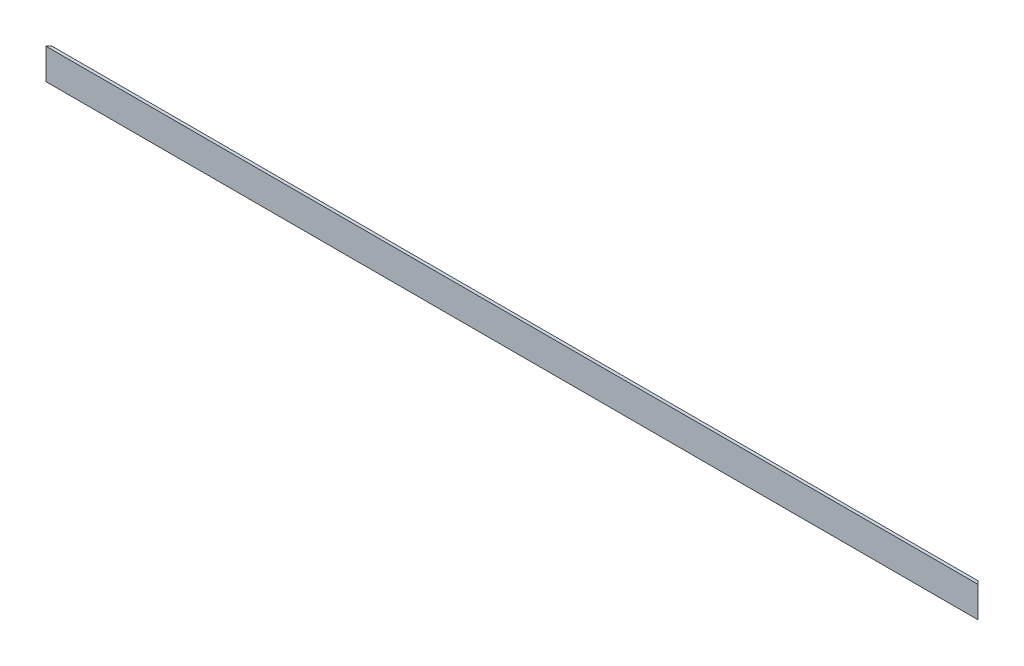
from build123d import *

# Parameters (mm, degrees)
EXTRUDE_1_DEPTH     = 455
CUT_EXTRUDE_1_DEPTH = 16


with BuildPart() as part:
    # Эскиз1 → Бобышка-Вытянуть1 (new body)
    with BuildSketch(Plane(origin=(0, 0, 0), x_dir=(0, 0, -1), z_dir=(1, 0, 0))):
        Polygon((0, 0), (0, 15), (1.5, 15), (1.5, 1.5), (15, 1.5), (15, 0), align=None)
    extrude(amount=EXTRUDE_1_DEPTH)

    # Эскиз2 → Вырез-Вытянуть1 (cut, through all)
    with BuildSketch(Plane.XZ):
        Polygon((455, 0), (434.173753179, -20.826246821), (455, -20.826246821), align=None)
    cut_extrude_1 = extrude(amount=-CUT_EXTRUDE_1_DEPTH, mode=Mode.SUBTRACT)

    # Зеркальное отражение1: Вырез-Вытянуть1 across plane
    add(cut_extrude_1.mirror(Plane(origin=(227.5, 0, 0), x_dir=(0, 0, 1), z_dir=(1, 0, 0))), mode=Mode.SUBTRACT)


solid = part.part
